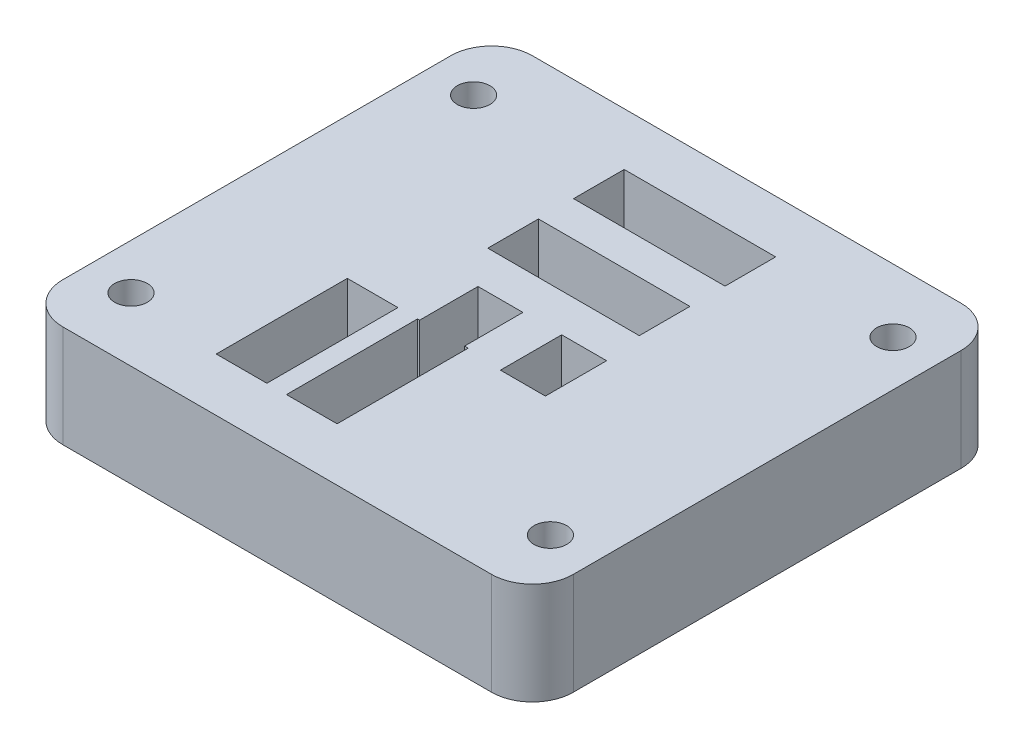
from build123d import *

# Parameters (mm, degrees)
SKETCH3_W           = 31.75
SKETCH3_H           = 29.21
BOSS_EXTRUDE2_DEPTH = 6.35
CUT_EXTRUDE1_DEPTH  = 0.8636
SKETCH6_R           = 1.016
CUT_EXTRUDE3_DEPTH  = 8.89
SKETCH4_W           = 9.4234
SKETCH4_H           = 3.1496
SKETCH4_W_2         = 3.1496
SKETCH4_H_2         = 8.1534
CUT_EXTRUDE2_DEPTH  = 6.4864
SKETCH7_W           = 2.794
SKETCH7_H           = 3.81
CUT_EXTRUDE4_DEPTH  = 6.4864
FILLET1_R           = 2.54
SKETCH9_R           = 0.4445
BOSS_EXTRUDE3_DEPTH = 0.8128
FILLET2_R           = 0.254


with BuildPart() as part:
    # Sketch3 → Boss-Extrude2 (new body)
    with BuildSketch(Plane(origin=(0, 0, 0), x_dir=(1, 0, 0), z_dir=(0, 1, 0))):
        Rectangle(SKETCH3_W, SKETCH3_H)
    extrude(amount=BOSS_EXTRUDE2_DEPTH)

    # Sketch1 → Cut-Extrude1 (cut)
    with BuildSketch(Plane(origin=(0, 0, 0), x_dir=(1, 0, 0), z_dir=(0, 1, 0))):
        with BuildLine():
            Line((11.967686493, 5.588), (11.967686493, -5.588))
            ThreePointArc((11.967686493, -5.588), (-13.208, 0), (11.967686493, 5.588))
        make_face()
    extrude(amount=CUT_EXTRUDE1_DEPTH, mode=Mode.SUBTRACT)

    # Sketch6 → Cut-Extrude3 (cut)
    with BuildSketch(Plane(origin=(0, 6.35, 0), x_dir=(1, 0, 0), z_dir=(0, 1, 0))):
        with Locations((-13.0429, 10.6553)):
            Circle(SKETCH6_R)
        with Locations((13.0429, 10.6553)):
            Circle(SKETCH6_R)
        with Locations((13.0429, -10.6553)):
            Circle(SKETCH6_R)
        with Locations((-13.0429, -10.6553)):
            Circle(SKETCH6_R)
    extrude(amount=-CUT_EXTRUDE3_DEPTH, mode=Mode.SUBTRACT)

    # Sketch4 → Cut-Extrude2 (cut, through all)
    with BuildSketch(Plane.XZ.offset(-0.8636)):
        with Locations((0.3556, -9.758937639)):
            Rectangle(SKETCH4_W, SKETCH4_H)
        with Locations((-5.5245, 7.220962361)):
            Rectangle(SKETCH4_W_2, SKETCH4_H_2)
        with Locations((0.3556, -4.424937639)):
            Rectangle(SKETCH4_W, SKETCH4_H)
        with Locations((-1.1557, 7.220962361)):
            Rectangle(SKETCH4_W_2, SKETCH4_H_2)
    extrude(amount=-CUT_EXTRUDE2_DEPTH, mode=Mode.SUBTRACT)

    # Sketch7 → Cut-Extrude4 (cut, through all)
    with BuildSketch(Plane.XZ.offset(-0.8636)):
        with Locations((-1.201434663, 1.4224)):
            Rectangle(SKETCH7_W, SKETCH7_H)
        with Locations((4.005565337, 1.4224)):
            Rectangle(SKETCH7_W, SKETCH7_H)
    extrude(amount=-CUT_EXTRUDE4_DEPTH, mode=Mode.SUBTRACT)

    # Fillet1
    fillet1_edges = [part.edges().sort_by_distance(p)[0] for p in [
        (-15.875, 3.175, -14.605),
        (15.875, 3.175, -14.605),
        (15.875, 3.175, 14.605),
        (-15.875, 3.175, 14.605),
    ]]
    fillet(fillet1_edges, radius=FILLET1_R)

    # Sketch9 → Boss-Extrude3 (add)
    with BuildSketch(Plane.XZ.offset(-0.8636)):
        with Locations((8.7503, 3.7592)):
            Circle(SKETCH9_R)
        with Locations((8.7503, -3.7592)):
            Circle(SKETCH9_R)
    extrude(amount=BOSS_EXTRUDE3_DEPTH)

    # Fillet2
    fillet2_edges = [part.edges().sort_by_distance(p)[0] for p in [
        (8.3058, 0.0508, 3.7592),
        (8.3058, 0.0508, -3.7592),
    ]]
    fillet(fillet2_edges, radius=FILLET2_R)


solid = part.part
